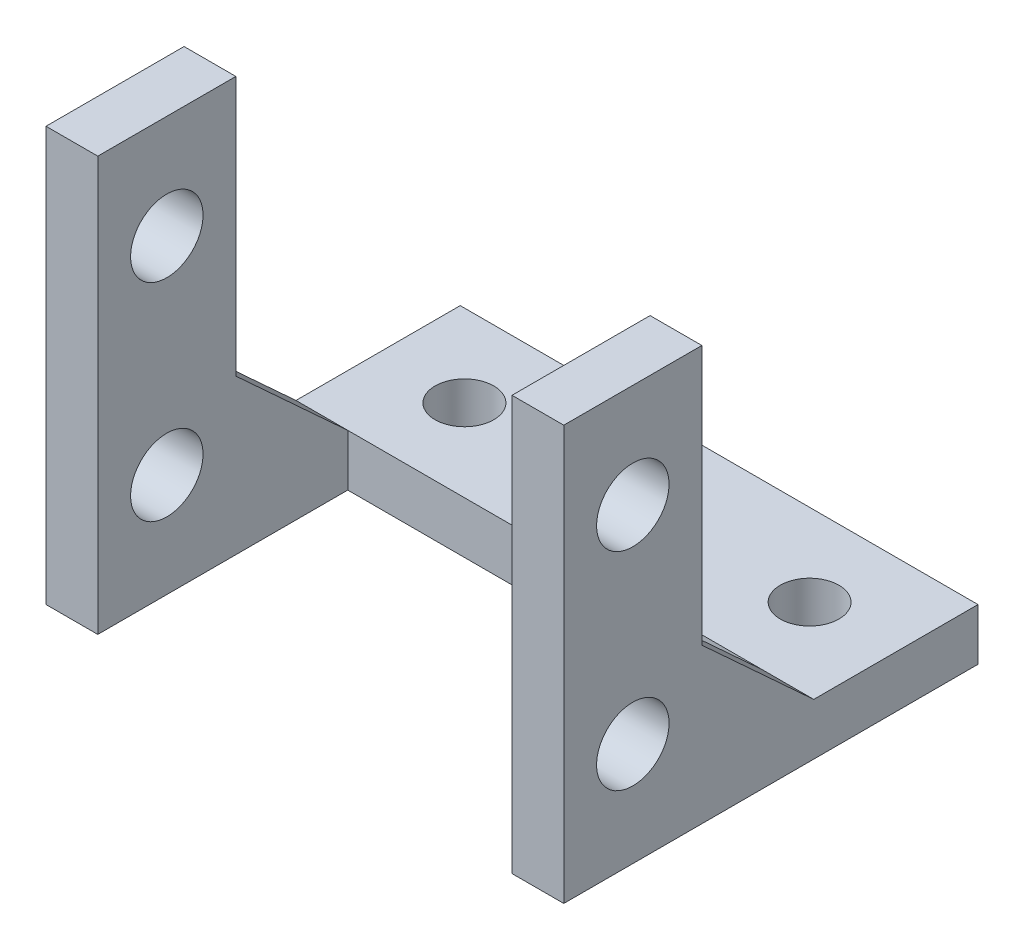
from build123d import *

# Parameters (mm, degrees)
SKETCH1_R           = 2.1
BOSS_EXTRUDE1_DEPTH = 15
CUT_EXTRUDE3_START  = -14.483913
SKETCH2_W           = 24
SKETCH2_H           = 24
CUT_EXTRUDE3_DEPTH  = 14.483913
CUT_EXTRUDE4_REACH  = 26
SKETCH3_R           = 1.7


with BuildPart() as part:
    # Sketch1 → Boss-Extrude1 (new body, symmetric)
    with BuildSketch(Plane(origin=(0, 0, 0), x_dir=(0, 0, -1), z_dir=(1, 0, 0))):
        Polygon((0, 0), (24, 0), (24, 3), (14.483913001, 3), (8, 8.960936807), (8, 24), (0, 24), align=None)
        with Locations((4, 6)):
            Circle(SKETCH1_R, mode=Mode.SUBTRACT)
        with Locations((4, 18)):
            Circle(SKETCH1_R, mode=Mode.SUBTRACT)
    extrude(amount=BOSS_EXTRUDE1_DEPTH, both=True)

    # Sketch2 → Cut-Extrude3 (cut)
    with BuildSketch(Plane.XY.offset(CUT_EXTRUDE3_START)):
        with Locations((0, 12)):
            Rectangle(SKETCH2_W, SKETCH2_H)
    extrude(amount=CUT_EXTRUDE3_DEPTH, mode=Mode.SUBTRACT)

    # Sketch3 → Cut-Extrude4 (cut, up to next)
    with BuildSketch(Plane(origin=(0, 0, 0), x_dir=(1, 0, 0), z_dir=(0, 1, 0)), mode=Mode.PRIVATE) as cut_extrude4_sk1:
        with Locations((-10, 19.241956501)):
            Circle(SKETCH3_R)
    cut_extrude4_tool1 = extrude(cut_extrude4_sk1.sketch, amount=CUT_EXTRUDE4_REACH, mode=Mode.PRIVATE) & part.part
    add(cut_extrude4_tool1.solids().sort_by_distance((-10, 0, -19.241957))[0], mode=Mode.SUBTRACT)
    # Sketch3 → Cut-Extrude4 (cut, up to next)
    with BuildSketch(Plane(origin=(0, 0, 0), x_dir=(1, 0, 0), z_dir=(0, 1, 0)), mode=Mode.PRIVATE) as cut_extrude4_sk2:
        with Locations((10, 19.241956501)):
            Circle(SKETCH3_R)
    cut_extrude4_tool2 = extrude(cut_extrude4_sk2.sketch, amount=CUT_EXTRUDE4_REACH, mode=Mode.PRIVATE) & part.part
    add(cut_extrude4_tool2.solids().sort_by_distance((10, 0, -19.241957))[0], mode=Mode.SUBTRACT)


solid = part.part
